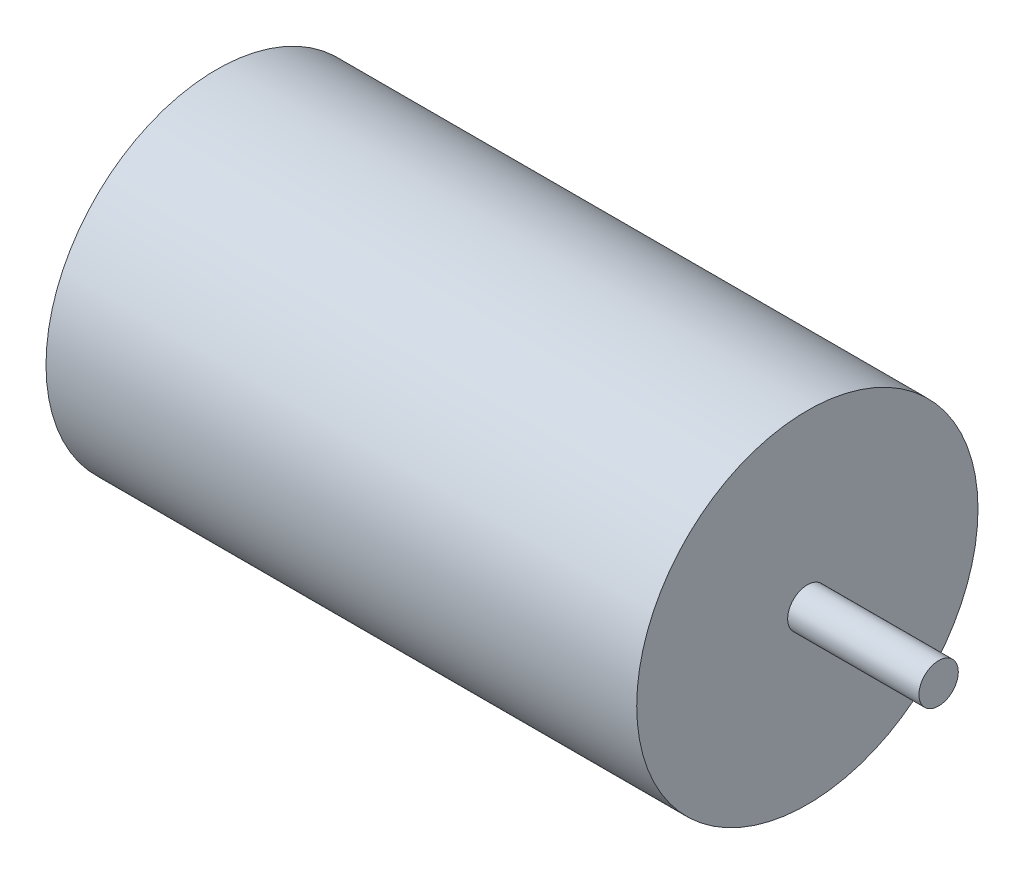
from build123d import *

# Parameters (mm, degrees)
SKETCH1_R           = 1.5
BOSS_EXTRUDE1_DEPTH = 10
SKETCH1_3_R         = 13
BOSS_EXTRUDE2_DEPTH = 45


with BuildPart() as part:
    # Sketch1 → Boss-Extrude1 (new body)
    with BuildSketch(Plane.YZ):
        Circle(SKETCH1_R)
    extrude(amount=BOSS_EXTRUDE1_DEPTH)

    # Sketch1_3 → Boss-Extrude2 (add)
    with BuildSketch(Plane.YZ):
        Circle(SKETCH1_3_R)
    extrude(amount=-BOSS_EXTRUDE2_DEPTH)


solid = part.part
